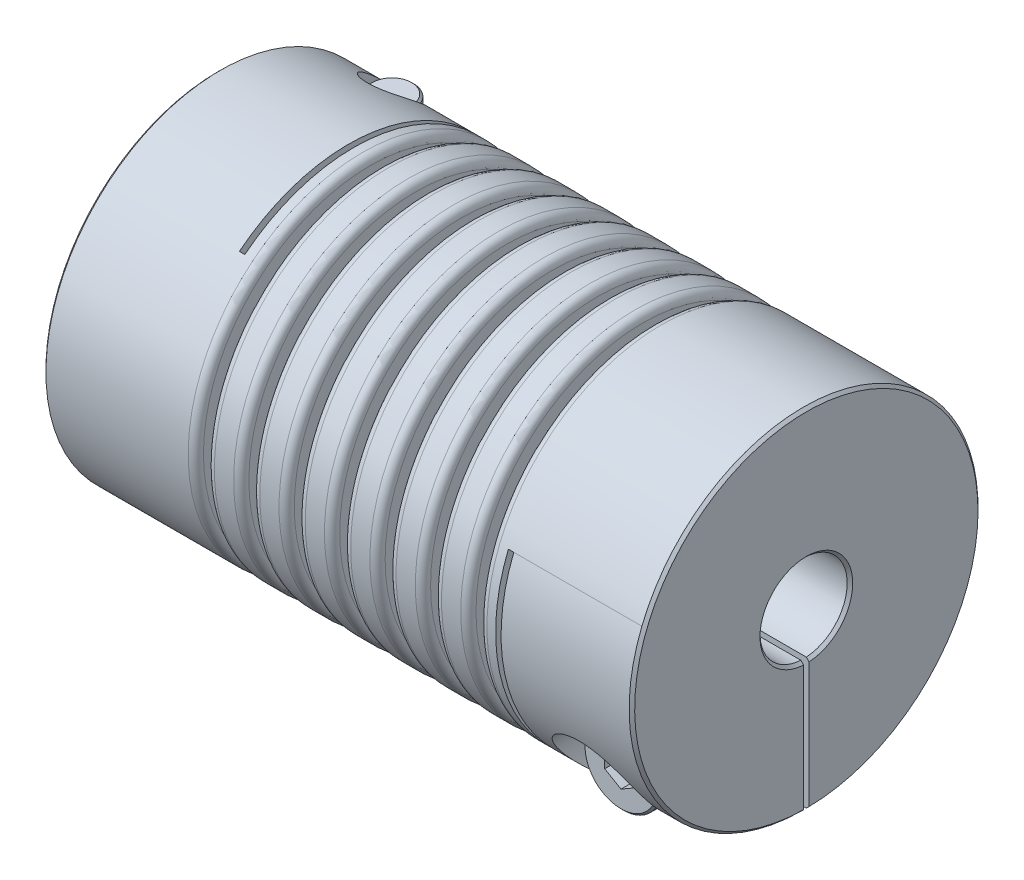
from build123d import *

# Parameters (mm, degrees)
SKETCH1_R                      = 16
BOSS_EXTRUDE1_DEPTH            = 27
SKETCH2_R                      = 4
CUT_EXTRUDE1_DEPTH             = 59.549124673
CHAMFER1_SIZE                  = 0.254
SKETCH4_W                      = 0.5
SKETCH4_H                      = 26
CUT_EXTRUDE2_DEPTH             = 45.821869662
SKETCH7_W                      = 0.5
SKETCH7_H                      = 22
CUT_EXTRUDE3_DEPTH             = 45.821869662
SKETCH8_W                      = 12
SKETCH8_H                      = 16
CUT_EXTRUDE5_DEPTH             = 0.25
SKETCH13_W                     = 12
SKETCH13_H                     = 16
CUT_EXTRUDE6_DEPTH             = 0.25
CBORE_FOR_M4_SHCS1_D           = 4.5
CBORE_FOR_M4_SHCS1_CBORE_D     = 8
CBORE_FOR_M4_SHCS1_CBORE_DEPTH = 9
CBORE_FOR_M4_SHCS2_D           = 4.5
CBORE_FOR_M4_SHCS2_CBORE_D     = 8
CBORE_FOR_M4_SHCS2_CBORE_DEPTH = 9
SKETCH16_R                     = 3.5
BOSS_EXTRUDE2_DEPTH            = 4
SKETCH17_R                     = 2
BOSS_EXTRUDE3_DEPTH            = 19
CHAMFER2_SIZE                  = 0.2
CUT_EXTRUDE7_DEPTH             = 1.5
CIRPATTERN1_COUNT              = 2
CIRPATTERN1_ANGLE              = 90
SKETCH19_W                     = 1
SKETCH19_H                     = 5.5
FILLET1_R                      = 0.7
FILLET2_R                      = 0.1


with BuildPart() as part:
    # Sketch1 → Boss-Extrude1 (new, symmetric)
    with BuildSketch(Plane(origin=(0, 0, 0), x_dir=(0, 0, -1), z_dir=(1, 0, 0))):
        Circle(SKETCH1_R)
    extrude(amount=BOSS_EXTRUDE1_DEPTH, both=True)

    # Sketch2 → Cut-Extrude1 (cut, through all)
    with BuildSketch(Plane(origin=(27, 0, 0), x_dir=(0, 0, -1), z_dir=(1, 0, 0))):
        Circle(SKETCH2_R)
    extrude(amount=-CUT_EXTRUDE1_DEPTH, mode=Mode.SUBTRACT)

    # Chamfer1
    chamfer1_edges = [part.edges().sort_by_distance(p)[0] for p in [
        (-27, 0, 16),
        (27, 0, 16),
        (-27, 0, 4),
        (27, 0, 4),
    ]]
    chamfer(chamfer1_edges, length=CHAMFER1_SIZE)

    # Sketch4 → Cut-Extrude2 (cut, through all)
    with BuildSketch(Plane.XZ.offset(16)):
        with Locations((-14.75, -3)):
            Rectangle(SKETCH4_W, SKETCH4_H)
    extrude(amount=-CUT_EXTRUDE2_DEPTH, mode=Mode.SUBTRACT)

    # Sketch7 → Cut-Extrude3 (cut, through all)
    with BuildSketch(Plane(origin=(0, 0, -16), x_dir=(-1, 0, 0), z_dir=(0, 0, -1))):
        with Locations((-14.75, -5)):
            Rectangle(SKETCH7_W, SKETCH7_H)
    extrude(amount=-CUT_EXTRUDE3_DEPTH, mode=Mode.SUBTRACT)

    # Sketch8 → Cut-Extrude5 (cut, symmetric)
    with BuildSketch(Plane(origin=(0, 0, 0), x_dir=(1, 0, 0), z_dir=(0, 1, 0))):
        with Locations((-21, 8)):
            Rectangle(SKETCH8_W, SKETCH8_H)
    extrude(amount=CUT_EXTRUDE5_DEPTH, both=True, mode=Mode.SUBTRACT)

    # Sketch13 → Cut-Extrude6 (cut, symmetric)
    with BuildSketch(Plane.XY):
        with Locations((21, -8)):
            Rectangle(SKETCH13_W, SKETCH13_H)
    extrude(amount=CUT_EXTRUDE6_DEPTH, both=True, mode=Mode.SUBTRACT)

    # CBORE for M4 SHCS1 (through all)
    with Locations(Plane.XZ.offset(16)):
        with Locations((-21, -9.995113306)):
            CounterBoreHole(CBORE_FOR_M4_SHCS1_D / 2, CBORE_FOR_M4_SHCS1_CBORE_D / 2, CBORE_FOR_M4_SHCS1_CBORE_DEPTH)

    # CBORE for M4 SHCS2 (through all)
    with Locations(Plane.XY.offset(16)):
        with Locations((21, -9.995113306)):
            CounterBoreHole(CBORE_FOR_M4_SHCS2_D / 2, CBORE_FOR_M4_SHCS2_CBORE_D / 2, CBORE_FOR_M4_SHCS2_CBORE_DEPTH)

    # Sketch19 → Cut-Revolve1 (revolve, cut)
    with BuildSketch(Plane.XY):
        with Locations((0, 13.25)):
            Rectangle(SKETCH19_W, SKETCH19_H)
        with Locations((4.166666667, 13.25)):
            Rectangle(SKETCH19_W, SKETCH19_H)
        with Locations((8.333333333, 13.25)):
            Rectangle(SKETCH19_W, SKETCH19_H)
        with Locations((12.5, 13.25)):
            Rectangle(SKETCH19_W, SKETCH19_H)
        with Locations((-12.5, 13.25)):
            Rectangle(SKETCH19_W, SKETCH19_H)
        with Locations((-8.333333333, 13.25)):
            Rectangle(SKETCH19_W, SKETCH19_H)
        with Locations((-4.166666667, 13.25)):
            Rectangle(SKETCH19_W, SKETCH19_H)
    revolve(axis=Axis((0, 0, 0), (-1, 0, 0)), mode=Mode.SUBTRACT)

    # Fillet1
    fillet1_edges = [part.edges().sort_by_distance(p)[0] for p in [
        (0.5, 0, 16),
        (-0.5, 0, 16),
        (-13, 0, 16),
        (-12, 0, 16),
        (4.666666667, 0, 16),
        (3.666666667, 0, 16),
        (8.833333333, 0, 16),
        (7.833333333, 0, 16),
        (13, 0, 16),
        (12, 0, 16),
        (-8.833333333, 0, 16),
        (-7.833333333, 0, 16),
        (-4.666666667, 0, 16),
        (-3.666666667, 0, 16),
    ]]
    fillet(fillet1_edges, radius=FILLET1_R)

    # Fillet2
    fillet2_edges = [part.edges().sort_by_distance(p)[0] for p in [
        (-0.5, -10.5, 0),
        (0.5, -10.5, 0),
        (-13, -10.5, 0),
        (-12, -10.5, 0),
        (3.666666667, -10.5, 0),
        (4.666666667, -10.5, 0),
        (7.833333333, -10.5, 0),
        (8.833333333, -10.5, 0),
        (12, -10.5, 0),
        (13, -10.5, 0),
        (-8.833333333, -10.5, 0),
        (-7.833333333, -10.5, 0),
        (-4.666666667, -10.5, 0),
        (-3.666666667, -10.5, 0),
    ]]
    fillet(fillet2_edges, radius=FILLET2_R)


with BuildPart() as body_2:
    # Sketch16 → Boss-Extrude2 (new body)
    with BuildSketch(Plane.XY.offset(7)):
        with Locations((21, -9.995113306)):
            Circle(SKETCH16_R)
    extrude(amount=BOSS_EXTRUDE2_DEPTH)

    # Sketch17 → Boss-Extrude3 (add)
    with BuildSketch(Plane(origin=(0, 0, 7), x_dir=(-1, 0, 0), z_dir=(0, 0, -1))):
        with Locations(Location((-21, -9.995113306, 0), (0, 0, 180))):
            Circle(SKETCH17_R)
    extrude(amount=BOSS_EXTRUDE3_DEPTH)

    # Chamfer2
    chamfer2_edges = [body_2.edges().sort_by_distance(p)[0] for p in [
        (17.5, -9.995113306, 7),
        (17.5, -9.995113306, 11),
        (19, -9.995113306, -12),
    ]]
    chamfer(chamfer2_edges, length=CHAMFER2_SIZE)

    # Sketch18 → Cut-Extrude7 (cut)
    with BuildSketch(Plane.XY.offset(11)):
        Polygon((21, -11.727164113), (22.5, -10.86113871), (22.5, -9.129087902), (21, -8.263062498), (19.5, -9.129087902), (19.5, -10.86113871), align=None)
    extrude(amount=-CUT_EXTRUDE7_DEPTH, mode=Mode.SUBTRACT)


with BuildPart() as body_3:
    # Mirror1: mirrored copy
    add(body_2.part.mirror(Plane(origin=(0, 0, 0), x_dir=(0, 0, 1), z_dir=(1, 0, 0))))


with BuildPart() as cirpattern1_1:
    # CirPattern1: pattern copy
    add(body_3.part.rotate(Axis((0, 0, 0), (1, 0, 0)), 1 * CIRPATTERN1_ANGLE / (CIRPATTERN1_COUNT - 1)))


solid = Compound([part.part, body_2.part, cirpattern1_1.part])
